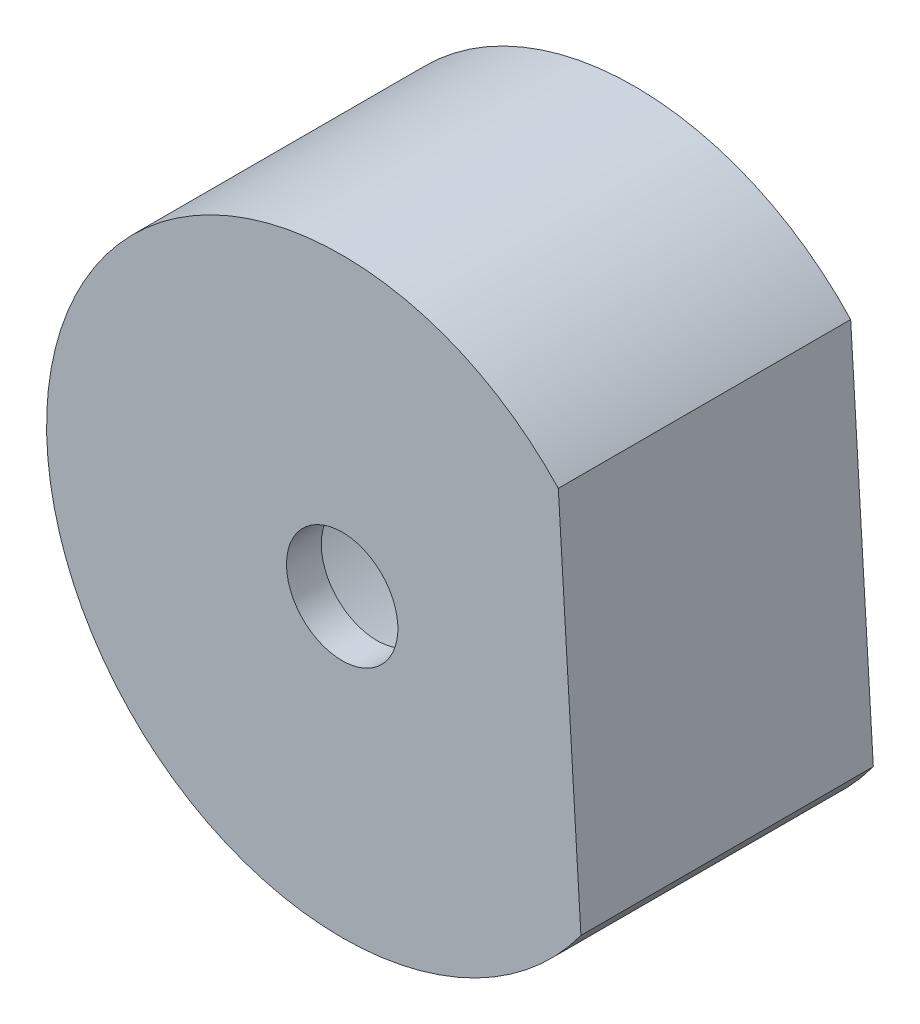
from build123d import *

# Parameters (mm, degrees)
SKETCH1_R            = 8.492006583
SKETCH1_R_2          = 5.992006583
BOSS_EXTRUDE1_DEPTH  = 7.4
SKETCH2_R            = 8.492006583
BOSS_EXTRUDE2_DEPTH  = 1
CUT_EXTRUDE1_DEPTH   = 18.3
M3_CLEARANCE_HOLE1_D = 3.2


with BuildPart() as part:
    # Sketch1 → Boss-Extrude1 (new body)
    with BuildSketch(Plane.XY):
        with Locations((78.5761931, -343.7069923)):
            Circle(SKETCH1_R)
        with Locations((78.5761931, -343.7069923)):
            Circle(SKETCH1_R_2, mode=Mode.SUBTRACT)
    extrude(amount=BOSS_EXTRUDE1_DEPTH)

    # Sketch2 → Boss-Extrude2 (add)
    with BuildSketch(Plane.XY.offset(7.4)):
        with Locations((78.5761931, -343.7069923)):
            Circle(SKETCH2_R)
    extrude(amount=BOSS_EXTRUDE2_DEPTH)

    # Sketch3 → Cut-Extrude1 (cut)
    with BuildSketch(Plane(origin=(0, 0, 0), x_dir=(-1, 0, 0), z_dir=(0, 0, -1))):
        with BuildLine():
            Line((-84.785347699, -337.913843331), (-85.435569051, -348.713302055))
            ThreePointArc((-85.435569051, -348.713302055), (-87.052849272, -343.196623866), (-84.785347699, -337.913843331))
        make_face()
    extrude(amount=-CUT_EXTRUDE1_DEPTH, mode=Mode.SUBTRACT)

    # M3 Clearance Hole1 (through all)
    with Locations(Plane(origin=(0, 0, 7.4), x_dir=(-1, 0, 0), z_dir=(0, 0, -1))):
        with Locations((-78.5761931, -343.7069923)):
            Hole(M3_CLEARANCE_HOLE1_D / 2)


solid = part.part
